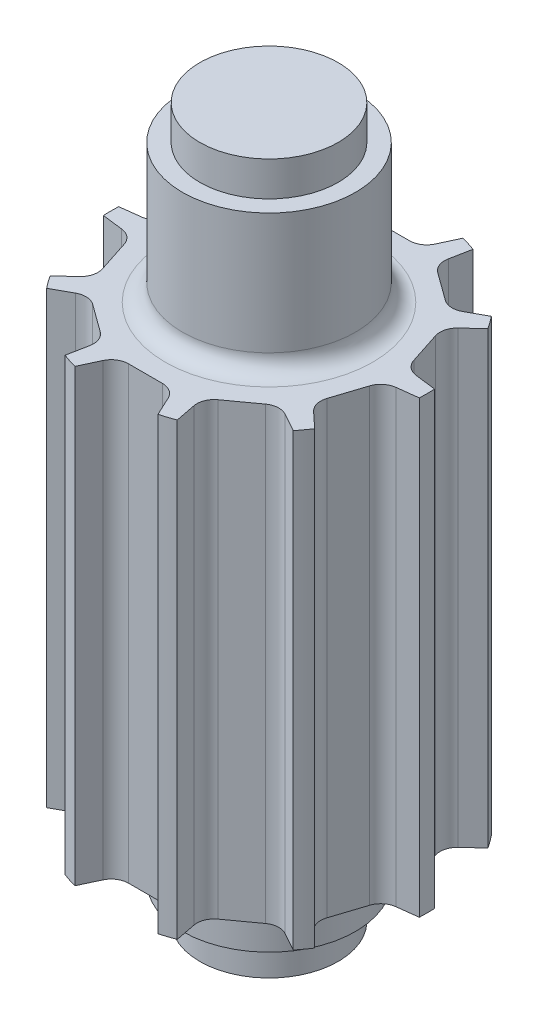
from build123d import *

# Parameters (mm, degrees)
SKIZZE1_R                       = 4.57
SKIZZE1_R_2                     = 2
AUFSATZ_LINEAR_AUSTRAGEN1_DEPTH = 13
SCHNITT_LINEAR_AUSTRAGEN1_DEPTH = 14
VERRUNDUNG1_R                   = 0.5
KREISMUSTER1_COUNT              = 10
VERRUNDUNG1_OF_KREISMUSTER1_R   = 0.5
FASE2_SIZE                      = 0.2
BOSS_EXTRUDE1_DEPTH             = 6.3
BOSS_EXTRUDE1_DEPTH_BACK        = 6.3
SKETCH2_R                       = 2.2
BOSS_EXTRUDE4_DEPTH             = 13
SKETCH3_R                       = 2
BOSS_EXTRUDE6_DEPTH             = 5
BOSS_EXTRUDE6_DEPTH_BACK        = 15.5
FILLET2_R                       = 0.5
SKETCH4_R                       = 2.5
SKETCH4_R_2                     = 1.5
BOSS_EXTRUDE7_DEPTH             = 1.5
FILLET3_R                       = 0.25
SKETCH5_R                       = 2.5
SKETCH5_R_2                     = 1.5
BOSS_EXTRUDE8_DEPTH             = 4
FILLET4_R                       = 0.5


with BuildPart() as part:
    # Skizze1 → Aufsatz-Linear austragen1 (new body)
    with BuildSketch(Plane(origin=(0, 0, 0), x_dir=(1, 0, 0), z_dir=(0, 1, 0))):
        Circle(SKIZZE1_R)
        Circle(SKIZZE1_R_2, mode=Mode.SUBTRACT)
    extrude(amount=AUFSATZ_LINEAR_AUSTRAGEN1_DEPTH)

    # Skizze12 → Schnitt-Linear austragen1 (cut, through all)
    with BuildSketch(Plane(origin=(0, 13, 0), x_dir=(1, 0, 0), z_dir=(0, 1, 0))):
        with BuildLine():
            Line((-1.2, 4.409637173), (-0.808470756, 3.57))
            Line((-0.808470756, 3.57), (0.808470756, 3.57))
            Line((0.808470756, 3.57), (1.2, 4.409637173))
            ThreePointArc((1.2, 4.409637173), (0, 4.57), (-1.2, 4.409637173))
        make_face()
    schnitt_linear_austragen1 = extrude(amount=-SCHNITT_LINEAR_AUSTRAGEN1_DEPTH, mode=Mode.SUBTRACT)

    # Verrundung1
    verrundung1_edges = [part.edges().sort_by_distance(p)[0] for p in [
        (0.808470756, 6.5, -3.57),
        (-0.808470756, 6.5, -3.57),
    ]]
    fillet(verrundung1_edges, radius=VERRUNDUNG1_R)

    # Kreismuster1: Schnitt-Linear austragen1 ×10 about axis
    kreismuster1_axis = Axis((0, 0, 0), (0, 1, 0))
    for i in range(1, KREISMUSTER1_COUNT):
        add(schnitt_linear_austragen1.rotate(kreismuster1_axis, i * 360 / KREISMUSTER1_COUNT), mode=Mode.SUBTRACT)

    # Verrundung1 of Kreismuster1
    verrundung1_of_kreismuster1_edges = [part.edges().sort_by_distance(p)[0] for p in [
        (-1.44432677, 6.5, -3.363397857),
        (-2.752459932, 6.5, -2.412983483),
        (-3.14544056, 6.5, -1.872092051),
        (-3.645102966, 6.5, -0.334289289),
        (-3.645102966, 6.5, 0.334289289),
        (-3.14544056, 6.5, 1.872092051),
        (-2.752459932, 6.5, 2.412983483),
        (-1.44432677, 6.5, 3.363397857),
        (-0.808470756, 6.5, 3.57),
        (0.808470756, 6.5, 3.57),
        (1.44432677, 6.5, 3.363397857),
        (2.752459932, 6.5, 2.412983483),
        (3.14544056, 6.5, 1.872092051),
        (3.645102966, 6.5, 0.334289289),
        (3.645102966, 6.5, -0.334289289),
        (3.14544056, 6.5, -1.872092051),
        (2.752459932, 6.5, -2.412983483),
        (1.44432677, 6.5, -3.363397857),
    ]]
    fillet(verrundung1_of_kreismuster1_edges, radius=VERRUNDUNG1_OF_KREISMUSTER1_R)

    # Fase2
    fase2_edges = [part.edges().sort_by_distance(p)[0] for p in [
        (-2, 0, 0),
        (-2, 13, 0),
    ]]
    chamfer(fase2_edges, length=FASE2_SIZE)

    # Sketch1 → Boss-Extrude1 (add, two sides)
    with BuildSketch(Plane(origin=(0, 6.5, 0), x_dir=(-1, 0, 0), z_dir=(0, -1, 0))) as boss_extrude1_sk:
        with BuildLine():
            Line((-1.4, 1.428285686), (-1.4, -1.428285686))
            ThreePointArc((-1.4, -1.428285686), (-2, 0), (-1.4, 1.428285686))
        make_face()
    extrude(amount=BOSS_EXTRUDE1_DEPTH)
    extrude(boss_extrude1_sk.sketch, amount=-BOSS_EXTRUDE1_DEPTH_BACK)



with BuildPart() as body_2:
    # Sketch2 → Boss-Extrude4 (new body)
    with BuildSketch(Plane(origin=(0, 13, 0), x_dir=(1, 0, 0), z_dir=(0, 1, 0))):
        Circle(SKETCH2_R)
    extrude(amount=-BOSS_EXTRUDE4_DEPTH)


with BuildPart() as part_1:
    add(part.part)

    add(body_2.part)  # Boss-Extrude6 merges body 2
    # Sketch3 → Boss-Extrude6 (add, two sides)
    with BuildSketch(Plane(origin=(0, 13, 0), x_dir=(1, 0, 0), z_dir=(0, 1, 0))) as boss_extrude6_sk:
        Circle(SKETCH3_R)
    extrude(amount=BOSS_EXTRUDE6_DEPTH)
    extrude(boss_extrude6_sk.sketch, amount=-BOSS_EXTRUDE6_DEPTH_BACK)

    # Fillet2
    fillet2_edges = [part_1.edges().sort_by_distance(p)[0] for p in [
        (-2, 13, 0),
        (-2, 0, 0),
    ]]
    fillet(fillet2_edges, radius=FILLET2_R)

    # Sketch4 → Boss-Extrude7 (add)
    with BuildSketch(Plane.XZ):
        Circle(SKETCH4_R)
        Circle(SKETCH4_R_2, mode=Mode.SUBTRACT)
    extrude(amount=BOSS_EXTRUDE7_DEPTH)

    # Fillet3
    fillet3_edges = [part_1.edges().sort_by_distance(p)[0] for p in [
        (-2.5, 0, 0),
    ]]
    fillet(fillet3_edges, radius=FILLET3_R)

    # Sketch5 → Boss-Extrude8 (add)
    with BuildSketch(Plane(origin=(0, 13, 0), x_dir=(1, 0, 0), z_dir=(0, 1, 0))):
        Circle(SKETCH5_R)
        Circle(SKETCH5_R_2, mode=Mode.SUBTRACT)
    extrude(amount=BOSS_EXTRUDE8_DEPTH)

    # Fillet4
    fillet4_edges = [part_1.edges().sort_by_distance(p)[0] for p in [
        (-2.5, 13, 0),
    ]]
    fillet(fillet4_edges, radius=FILLET4_R)


solid = part_1.part
